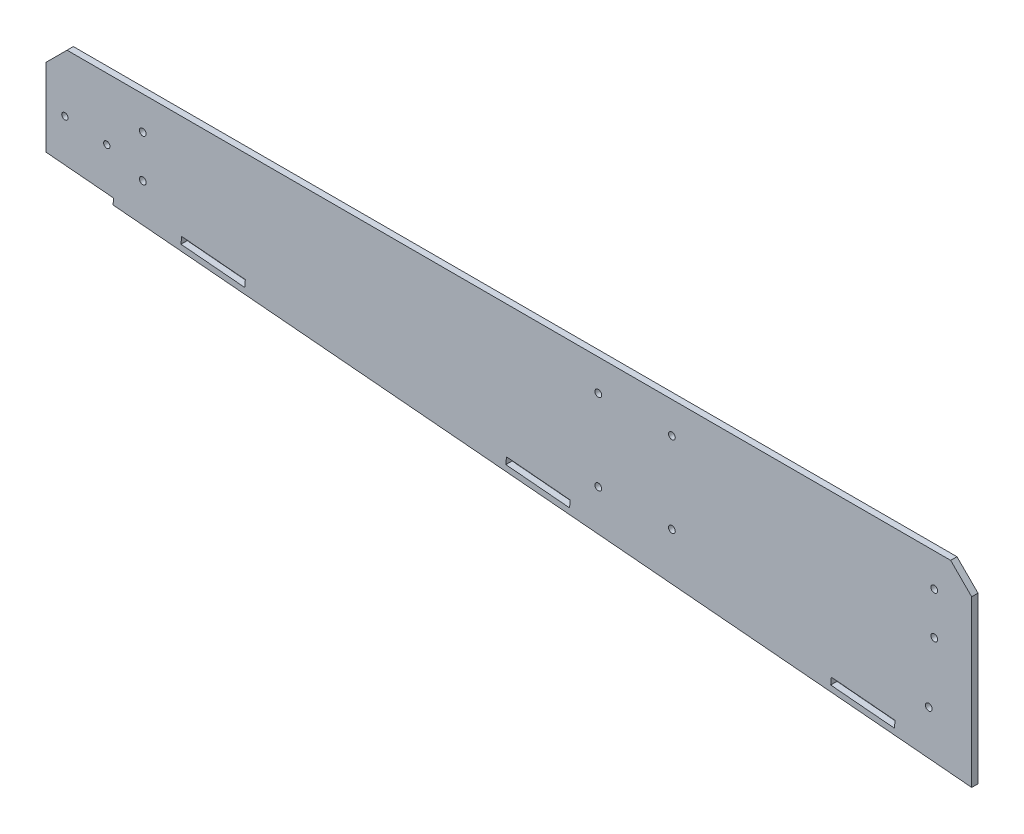
from build123d import *

# Parameters (mm, degrees)
EXTRUDE_1_DEPTH     = 3
CUT_EXTRUDE_2_DEPTH = 10
SKETCH1_R           = 1.5
SKETCH1_R_2         = 1.6
CUT_EXTRUDE2_DEPTH  = 3
CHAMFER1_SIZE       = 10
SKETCH2_R           = 1.6
CUT_EXTRUDE3_DEPTH  = 10
SKETCH3_R           = 1.6
CUT_EXTRUDE4_DEPTH  = 39


with BuildPart() as part:
    # 草图1 → 凸台-拉伸1 (new body)
    with BuildSketch(Plane.XY):
        Polygon((-31.770103996, 71.767703031), (408.229896004, 71.767703031), (408.229896004, -16.727308921), (-31.770103996, 21.767703031), align=None)
    extrude(amount=EXTRUDE_1_DEPTH)

    # 草图3 → 切除-拉伸2 (cut)
    with BuildSketch(Plane.XY.offset(3)):
        Polygon((0.108126343, 18.978719263), (0.369593572, 21.967303357), (-31.770103996, 24.779162543), (-31.770103996, 21.767703031), align=None)
        Polygon((371.792330274, -7.315752), (371.496000749, -10.702813974), (341.211681927, -8.053279394), (341.508011452, -4.666217421), align=None)
        Polygon((217.38215207, 6.193388126), (217.085822544, 2.806326152), (186.801503722, 5.455860732), (187.097833248, 8.842922705), align=None)
        Polygon((62.971973866, 19.702528252), (62.67564434, 16.315466278), (32.391325518, 18.965000858), (32.687655044, 22.352062831), align=None)
    extrude(amount=-CUT_EXTRUDE_2_DEPTH, mode=Mode.SUBTRACT)

    # Sketch1 → Cut-Extrude2 (cut)
    with BuildSketch(Plane(origin=(0, 0, 0), x_dir=(-1, 0, 0), z_dir=(0, 0, -1))):
        with Locations((22.792159026, 44.070090887)):
            Circle(SKETCH1_R)
        with Locations((2.868265064, 42.326976033)):
            Circle(SKETCH1_R)
        with Locations((-230.729896004, 56.783526399)):
            Circle(SKETCH1_R_2)
        with Locations((-230.729896004, 18.2779729)):
            Circle(SKETCH1_R_2)
        with Locations((-265.729896004, 18.2779729)):
            Circle(SKETCH1_R_2)
        with Locations((-265.729896004, 56.783526399)):
            Circle(SKETCH1_R_2)
    extrude(amount=-CUT_EXTRUDE2_DEPTH, mode=Mode.SUBTRACT)

    # Chamfer1
    chamfer1_edges = [part.edges().sort_by_distance(p)[0] for p in [
        (-31.770103996, 71.767703031, 1.5),
        (408.229896004, 71.767703031, 1.5),
    ]]
    chamfer(chamfer1_edges, length=CHAMFER1_SIZE)

    # Sketch2 → Cut-Extrude3 (cut)
    with BuildSketch(Plane(origin=(0, 0, 0), x_dir=(-1, 0, 0), z_dir=(0, 0, -1))):
        with Locations((-390.440589081, 36.023865482)):
            Circle(SKETCH2_R)
        with Locations((-387.825916798, 6.138024539)):
            Circle(SKETCH2_R)
    extrude(amount=-CUT_EXTRUDE3_DEPTH, mode=Mode.SUBTRACT)

    # Sketch3 → Cut-Extrude4 (cut)
    with BuildSketch(Plane(origin=(0, 0, 0), x_dir=(-1, 0, 0), z_dir=(0, 0, -1))):
        with Locations((-390.440589081, 56.023865482)):
            Circle(SKETCH3_R)
        with Locations((-14.229896004, 36.023865482)):
            Circle(SKETCH3_R)
        with Locations((-14.229896004, 56.023865482)):
            Circle(SKETCH3_R)
    extrude(amount=-CUT_EXTRUDE4_DEPTH, mode=Mode.SUBTRACT)


solid = part.part
